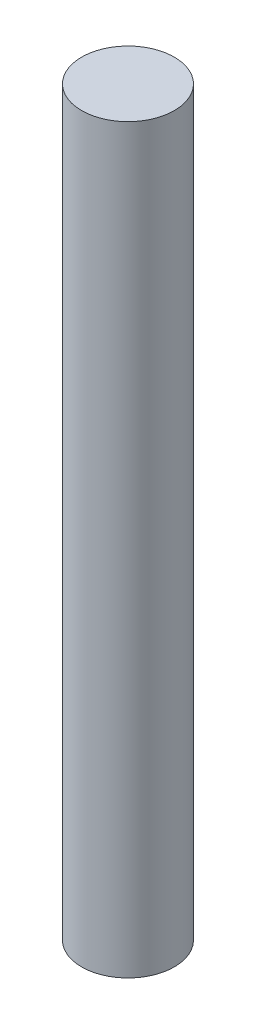
from build123d import *

# Parameters (mm, degrees)
SKETCH1_R           = 3
BOSS_EXTRUDE1_DEPTH = 48


with BuildPart() as part:
    # Sketch1 → Boss-Extrude1 (new body)
    with BuildSketch(Plane(origin=(0, 0, 0), x_dir=(1, 0, 0), z_dir=(0, 1, 0))):
        with Locations(Location((0, 0, 0), (0, 0, 270))):  # turned: the seam where the file's is
            Circle(SKETCH1_R)
    extrude(amount=BOSS_EXTRUDE1_DEPTH)


solid = part.part
